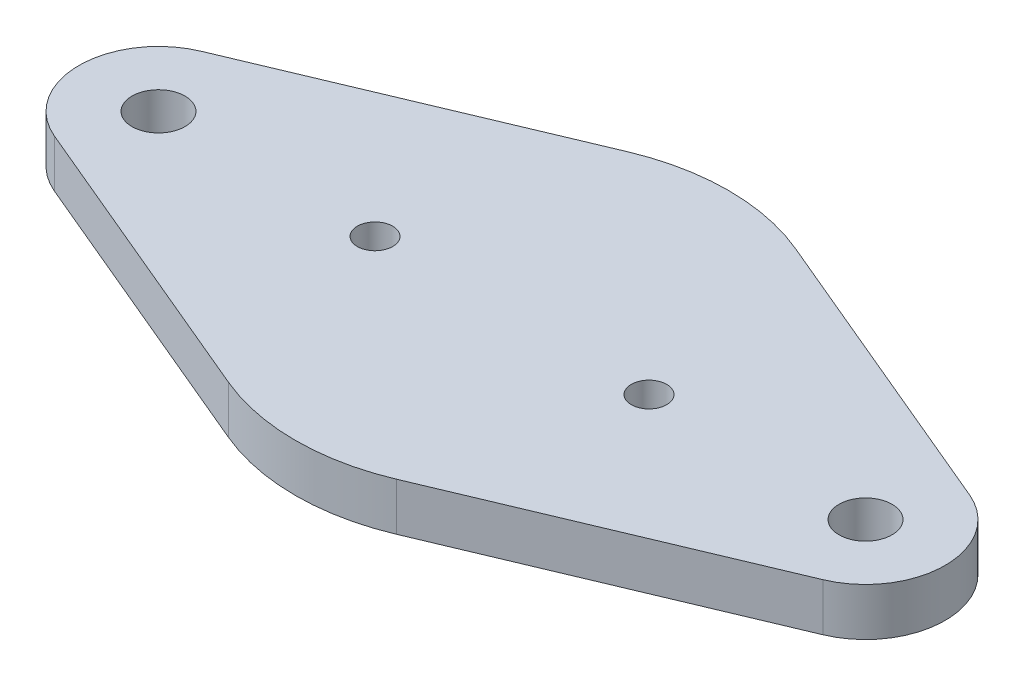
from build123d import *

# Parameters (mm, degrees)
BOSS_EXTRUDE1_DEPTH = 2.7
CUT_EXTRUDE1_REACH  = 4.7
SKETCH2_R           = 1.5
SKETCH2_R_2         = 1


with BuildPart() as part:
    # Sketch1 → Boss-Extrude1 (new body)
    with BuildSketch(Plane(origin=(0, 0, 0), x_dir=(1, 0, 0), z_dir=(0, 1, 0))):
        with BuildLine():
            Line((4.746875, 11.292903866), (21.74375, 4.148413665))
            ThreePointArc((21.74375, 4.148413665), (24.5, 0), (21.74375, -4.148413665))
            Line((21.74375, -4.148413665), (4.746875, -11.292903866))
            ThreePointArc((4.746875, -11.292903866), (0, -12.25), (-4.746875, -11.292903866))
            Line((-4.746875, -11.292903866), (-21.74375, -4.148413665))
            ThreePointArc((-21.74375, -4.148413665), (-24.5, 0), (-21.74375, 4.148413665))
            Line((-21.74375, 4.148413665), (-4.746875, 11.292903866))
            ThreePointArc((-4.746875, 11.292903866), (0, 12.25), (4.746875, 11.292903866))
        make_face()
    extrude(amount=BOSS_EXTRUDE1_DEPTH)

    # Sketch2 → Cut-Extrude1 (cut, up to next)
    with BuildSketch(Plane(origin=(0, 2.7, 0), x_dir=(1, 0, 0), z_dir=(0, 1, 0)), mode=Mode.PRIVATE) as cut_extrude1_sk1:
        with Locations((-20, 0)):
            Circle(SKETCH2_R)
    cut_extrude1_tool1 = extrude(cut_extrude1_sk1.sketch, amount=-CUT_EXTRUDE1_REACH, mode=Mode.PRIVATE) & part.part
    add(cut_extrude1_tool1.solids().sort_by_distance((-20, 2.7, 0))[0], mode=Mode.SUBTRACT)
    # Sketch2 → Cut-Extrude1 (cut, up to next)
    with BuildSketch(Plane(origin=(0, 2.7, 0), x_dir=(1, 0, 0), z_dir=(0, 1, 0)), mode=Mode.PRIVATE) as cut_extrude1_sk2:
        with Locations((20, 0)):
            Circle(SKETCH2_R)
    cut_extrude1_tool2 = extrude(cut_extrude1_sk2.sketch, amount=-CUT_EXTRUDE1_REACH, mode=Mode.PRIVATE) & part.part
    add(cut_extrude1_tool2.solids().sort_by_distance((20, 2.7, 0))[0], mode=Mode.SUBTRACT)
    # Sketch2 → Cut-Extrude1 (cut, up to next)
    with BuildSketch(Plane(origin=(0, 2.7, 0), x_dir=(1, 0, 0), z_dir=(0, 1, 0)), mode=Mode.PRIVATE) as cut_extrude1_sk3:
        with Locations((7.75, 0)):
            Circle(SKETCH2_R_2)
    cut_extrude1_tool3 = extrude(cut_extrude1_sk3.sketch, amount=-CUT_EXTRUDE1_REACH, mode=Mode.PRIVATE) & part.part
    add(cut_extrude1_tool3.solids().sort_by_distance((7.75, 2.7, 0))[0], mode=Mode.SUBTRACT)
    # Sketch2 → Cut-Extrude1 (cut, up to next)
    with BuildSketch(Plane(origin=(0, 2.7, 0), x_dir=(1, 0, 0), z_dir=(0, 1, 0)), mode=Mode.PRIVATE) as cut_extrude1_sk4:
        with Locations((-7.75, 0)):
            Circle(SKETCH2_R_2)
    cut_extrude1_tool4 = extrude(cut_extrude1_sk4.sketch, amount=-CUT_EXTRUDE1_REACH, mode=Mode.PRIVATE) & part.part
    add(cut_extrude1_tool4.solids().sort_by_distance((-7.75, 2.7, 0))[0], mode=Mode.SUBTRACT)


solid = part.part
